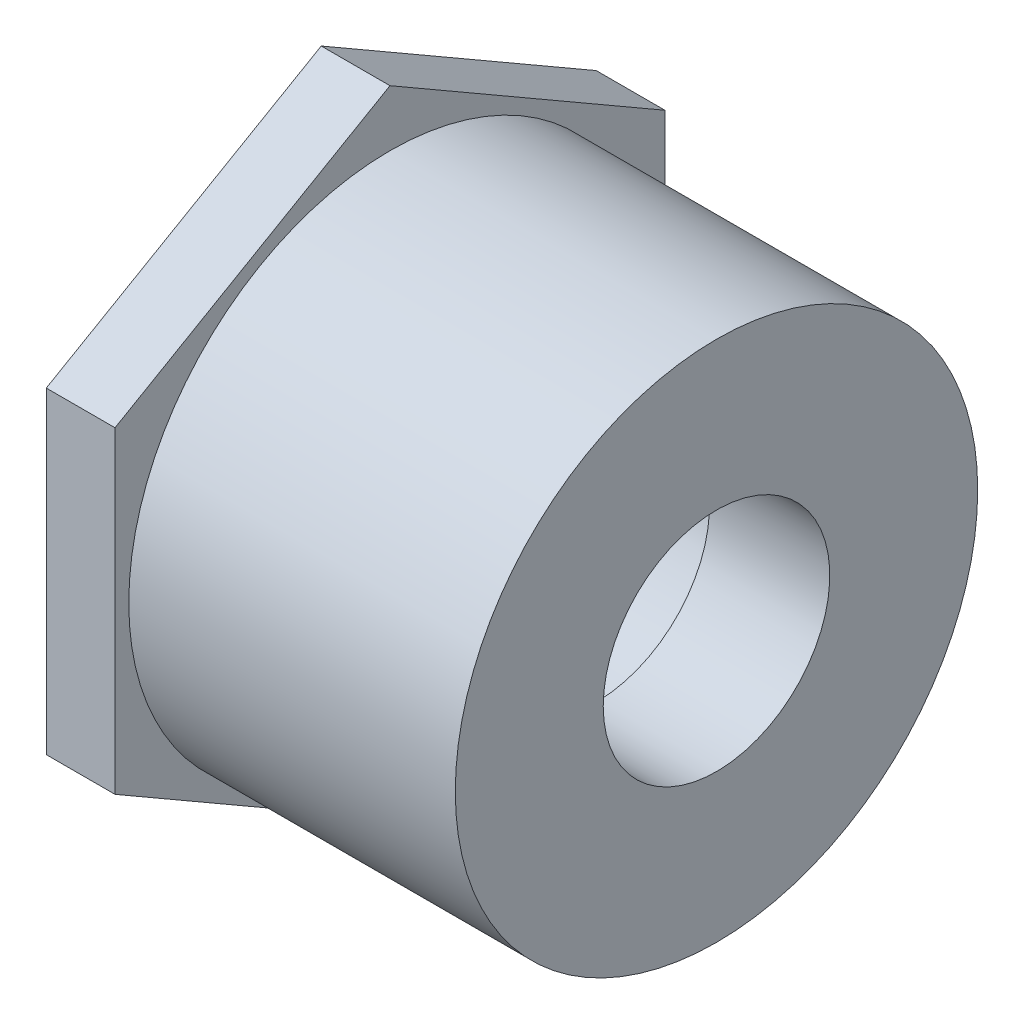
from build123d import *

# Parameters (mm, degrees)
SKETCH2_R           = 13.4366
BOSS_EXTRUDE1_DEPTH = 6.35


with BuildPart() as part:
    # Sketch1 → Revolve1 (revolve)
    with BuildSketch(Plane.XY):
        Polygon((-36.5125, -24.13), (0, -24.13), (0, -10.4648), (-11.1125, -10.4648), (-11.1125, -13.2842), (-36.5125, -13.4366), align=None)
    revolve(axis=Axis((-36.5125, 0, 0), (1, 0, 0)))

    # Sketch2 → Boss-Extrude1 (add)
    with BuildSketch(Plane.ZY.offset(36.5125)):
        Polygon((0, 29.329393675), (-25.4, 14.664696837), (-25.4, -14.664696837), (0, -29.329393675), (25.4, -14.664696837), (25.4, 14.664696837), align=None)
        Circle(SKETCH2_R, mode=Mode.SUBTRACT)
    extrude(amount=-BOSS_EXTRUDE1_DEPTH)


solid = part.part
